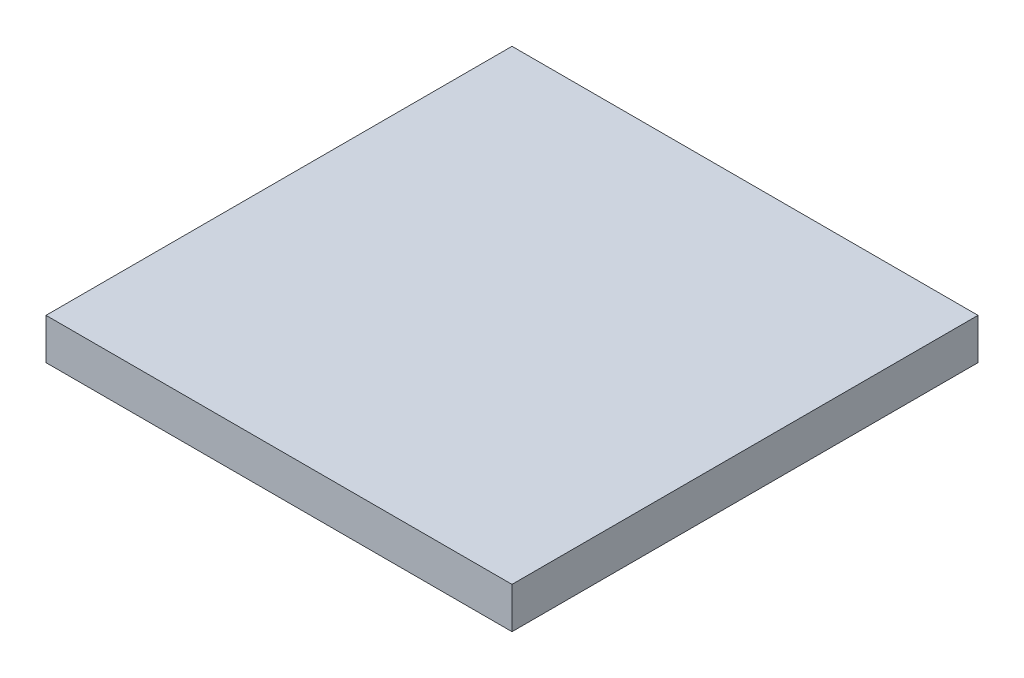
from build123d import *

# Parameters (mm, degrees)
SKETCH_1_W      = 12.5
SKETCH_1_H      = 12.5
EXTRUDE_1_DEPTH = 1.1


with BuildPart() as part:
    # 草图1 → 凸台-拉伸1 (new body)
    with BuildSketch(Plane(origin=(0, 0, 0), x_dir=(1, 0, 0), z_dir=(0, 1, 0))):
        Rectangle(SKETCH_1_W, SKETCH_1_H)
    extrude(amount=EXTRUDE_1_DEPTH)


solid = part.part
